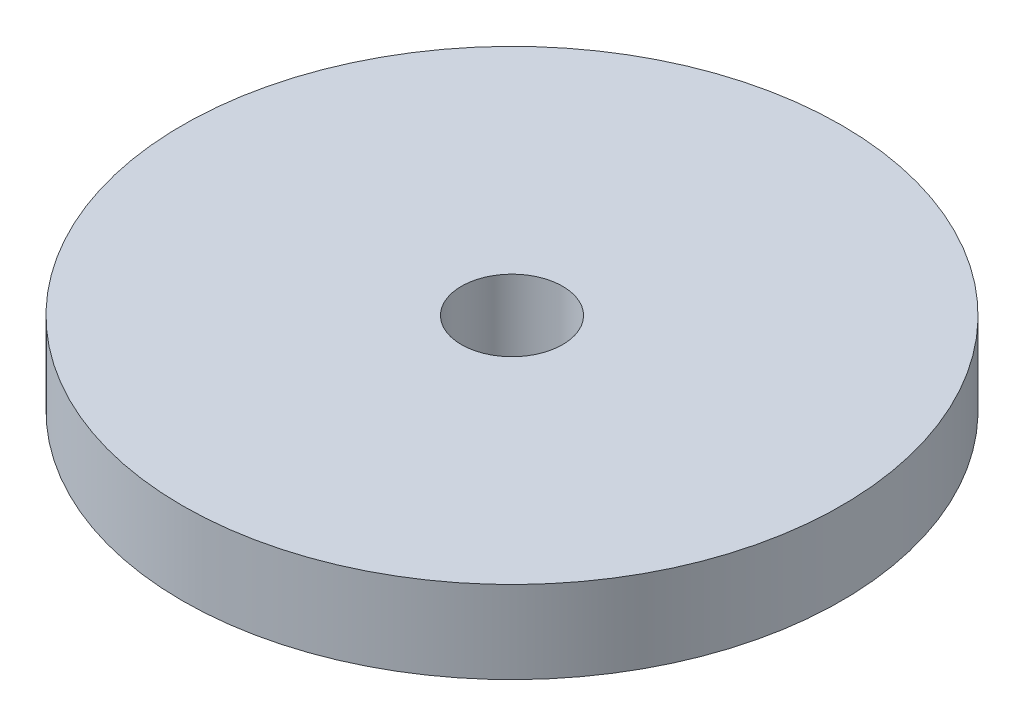
from build123d import *

# Parameters (mm, degrees)
SKETCH1_R           = 14
BOSS_EXTRUDE1_DEPTH = 4
SKETCH2_R           = 14
SKETCH2_R_2         = 6.5
CUT_EXTRUDE1_DEPTH  = 0.5
SKETCH3_R           = 2.15
CUT_EXTRUDE2_DEPTH  = 4


with BuildPart() as part:
    # Sketch1 → Boss-Extrude1 (new body)
    with BuildSketch(Plane(origin=(0, 0, 0), x_dir=(1, 0, 0), z_dir=(0, 1, 0))):
        Circle(SKETCH1_R)
    extrude(amount=BOSS_EXTRUDE1_DEPTH)

    # Sketch2 → Cut-Extrude1 (cut)
    with BuildSketch(Plane.XZ):
        Circle(SKETCH2_R)
        Circle(SKETCH2_R_2, mode=Mode.SUBTRACT)
    extrude(amount=-CUT_EXTRUDE1_DEPTH, mode=Mode.SUBTRACT)

    # Sketch3 → Cut-Extrude2 (cut)
    with BuildSketch(Plane(origin=(0, 4, 0), x_dir=(1, 0, 0), z_dir=(0, 1, 0))):
        Circle(SKETCH3_R)
    extrude(amount=-CUT_EXTRUDE2_DEPTH, mode=Mode.SUBTRACT)


solid = part.part
